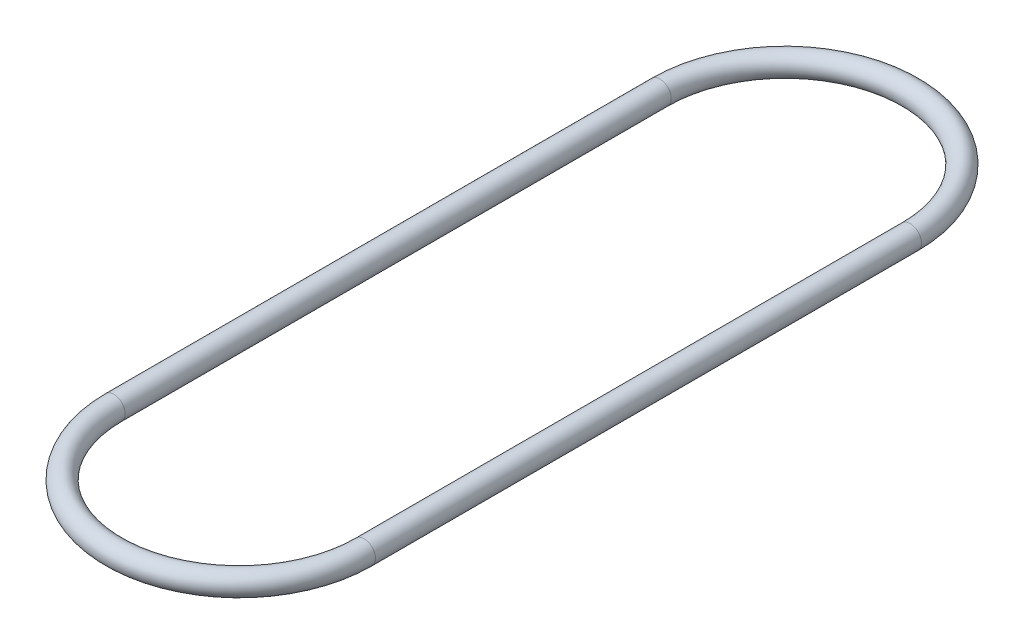
from build123d import *

# Parameters (mm, degrees)
SKETCH1_R = 3.175


with BuildPart() as part:
    # Sweep1: sweep along a path in Sketch2
    with BuildLine(Plane(origin=(0, 0, 0), x_dir=(1, 0, 0), z_dir=(0, 1, 0))) as sweep1_path:
        Line((0, 0), (0, 152.4))
        ThreePointArc((0, 152.4), (34.925, 187.325), (69.85, 152.4))
        Line((69.85, 152.4), (69.85, 0))
        ThreePointArc((69.85, 0), (34.925, -34.925), (0, 0))
    # Sketch1 → Sweep1 (sweep)
    with BuildSketch(Plane.XY):
        Circle(SKETCH1_R)
    sweep(path=sweep1_path.line)


solid = part.part
